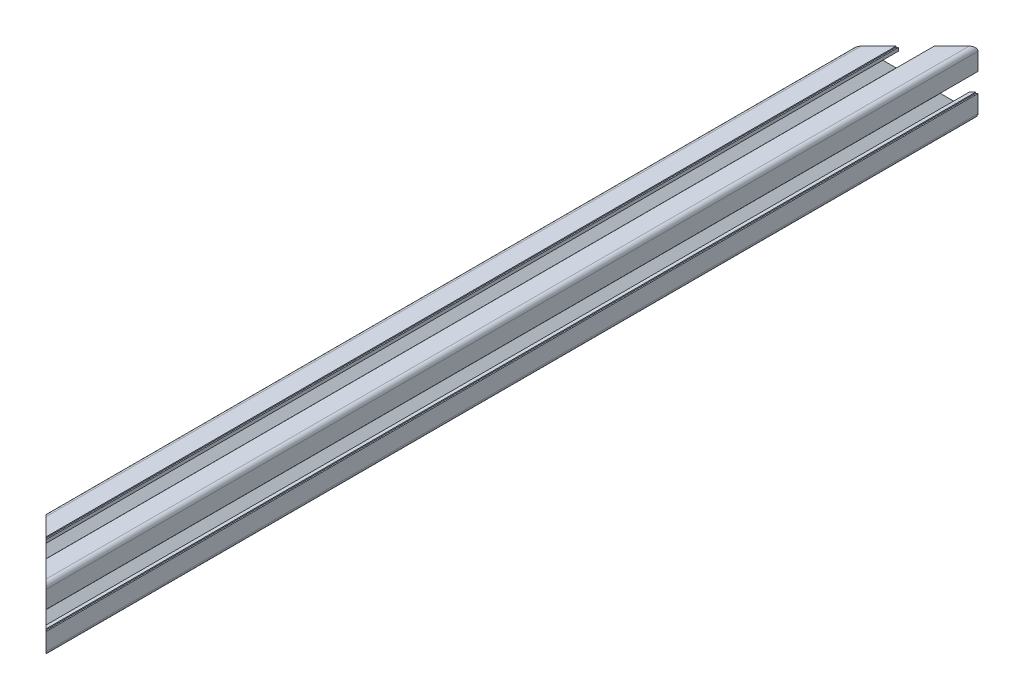
from build123d import *

# Parameters (mm, degrees)
BOSS_EXTRUDE1_DEPTH     = 444.5
CUT_EXTRUDE1_DEPTH      = 1
CUT_EXTRUDE1_DEPTH_BACK = 445.5
CUT_EXTRUDE2_DEPTH      = 31


with BuildPart() as part:
    # Sketch4 → Boss-Extrude1 (new body)
    with BuildSketch(Plane.XY):
        with BuildLine():
            Line((0, -5.45), (0.655464476, -6))
            Line((0.655464476, -6), (4.504469158, -6))
            Line((4.504469158, -6), (8.25, -9.745530842))
            Line((8.25, -9.745530842), (8.25, -12.885))
            Line((8.25, -12.885), (4, -12.885))
            Line((4, -12.885), (4, -14.45))
            Line((4, -14.45), (4.55, -14.45))
            Line((4.55, -14.45), (4.55, -15))
            Line((4.55, -15), (12.885, -15))
            ThreePointArc((12.885, -15), (14.380530842, -14.380530842), (15, -12.885))
            Line((15, -12.885), (15, -4.55))
            Line((15, -4.55), (14.45, -4.55))
            Line((14.45, -4.55), (14.45, -4))
            Line((14.45, -4), (12.885, -4))
            Line((12.885, -4), (12.885, -8.25))
            Line((12.885, -8.25), (9.745530842, -8.25))
            Line((9.745530842, -8.25), (6, -4.504469158))
            Line((6, -4.504469158), (6, -0.655464476))
            Line((6, -0.655464476), (5.45, 0))
            Line((5.45, 0), (3.5, 0))
            ThreePointArc((3.5, 0), (3.371433308, -0.939913534), (2.995178599, -1.81077474))
            Line((2.995178599, -1.81077474), (4.675743591, -3.491339732))
            Line((4.675743591, -3.491339732), (3.491339732, -4.675743591))
            Line((3.491339732, -4.675743591), (1.81077474, -2.995178599))
            ThreePointArc((1.81077474, -2.995178599), (0.939913534, -3.371433308), (0, -3.5))
            Line((0, -3.5), (0, -5.45))
        make_face()
        with BuildLine():
            Line((9.375, -10.365), (9.375, -12.885))
            ThreePointArc((9.375, -12.885), (9.664964287, -13.585035713), (10.365, -13.875))
            Line((10.365, -13.875), (12.885, -13.875))
            ThreePointArc((12.885, -13.875), (13.585035713, -13.585035713), (13.875, -12.885))
            Line((13.875, -12.885), (13.875, -10.365))
            ThreePointArc((13.875, -10.365), (13.585035713, -9.664964287), (12.885, -9.375))
            Line((12.885, -9.375), (10.365, -9.375))
            ThreePointArc((10.365, -9.375), (9.664964287, -9.664964287), (9.375, -10.365))
        make_face(mode=Mode.SUBTRACT)
    extrude(amount=BOSS_EXTRUDE1_DEPTH)

    # Mirror1: part across plane


with BuildPart() as part_1:
    add(part.part)
    add(part.part.mirror(Plane(origin=(0, 0, 0), x_dir=(0, 0, 1), z_dir=(1, 0, 0))))

    # Mirror2: part across plane


with BuildPart() as part_2:
    add(part_1.part)
    add(part_1.part.mirror(Plane.ZX))

    # Sketch5 → Cut-Extrude1 (cut, two sides)
    with BuildSketch(Plane.XY.offset(444.5)) as cut_extrude1_sk:
        Polygon((-5.675, 12.885), (-5.4, 13.16), (-5.125, 12.885), align=None)
    extrude(amount=CUT_EXTRUDE1_DEPTH, mode=Mode.SUBTRACT)
    extrude(cut_extrude1_sk.sketch, amount=-CUT_EXTRUDE1_DEPTH_BACK, mode=Mode.SUBTRACT)

    # Sketch6 → Cut-Extrude2 (cut, through all)
    with BuildSketch(Plane.XZ.offset(15)):
        Polygon((15, 444.5), (-15, 444.5), (-15, 414.5), align=None)
        Polygon((15, 0), (-15, 0), (-15, 30), align=None)
    extrude(amount=-CUT_EXTRUDE2_DEPTH, mode=Mode.SUBTRACT)


solid = part_2.part
